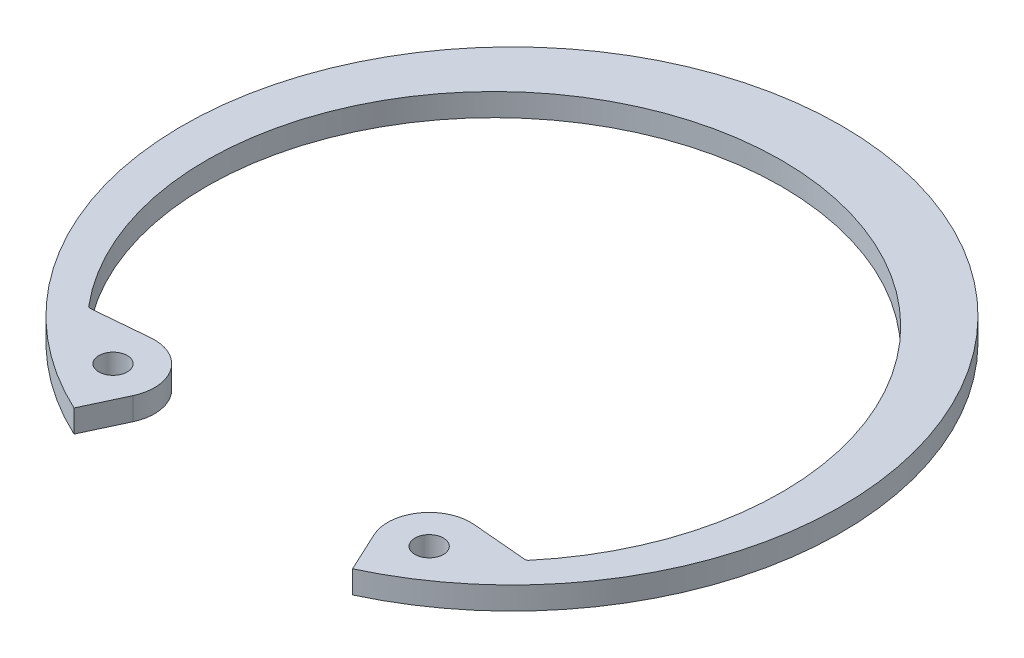
from build123d import *

# Parameters (mm, degrees)
SKETCH2_R      = 0.9906
EXTRUDE1_DEPTH = 1.5748
FILLET1_R      = 0.254


with BuildPart() as part:
    # Sketch2 → Extrude1 (new body)
    with BuildSketch(Plane(origin=(0, 0, 0), x_dir=(1, 0, 0), z_dir=(0, 1, 0))):
        with BuildLine():
            Line((9.682522471, -20.764236447), (8.376008921, -17.962409097))
            ThreePointArc((8.376008921, -17.962409097), (8.627270212, -15.090479402), (11.240064931, -13.872113215))
            Line((11.240064931, -13.872113215), (15.218174681, -14.22015272))
            ThreePointArc((15.218174681, -14.22015272), (0, 18.7452), (-15.218174681, -14.22015272))
            Line((-15.218174681, -14.22015272), (-11.240064931, -13.872113215))
            ThreePointArc((-11.240064931, -13.872113215), (-8.627270212, -15.090479402), (-8.376008921, -17.962409097))
            Line((-8.376008921, -17.962409097), (-9.682522471, -20.764236447))
            ThreePointArc((-9.682522471, -20.764236447), (0, 22.9108), (9.682522471, -20.764236447))
        make_face()
        with Locations((10.98880364, -16.74404291)):
            Circle(SKETCH2_R, mode=Mode.SUBTRACT)
        with Locations((-10.98880364, -16.74404291)):
            Circle(SKETCH2_R, mode=Mode.SUBTRACT)
    extrude(amount=-EXTRUDE1_DEPTH)

    # Fillet1
    fillet1_edges = [part.edges().sort_by_distance(p)[0] for p in [
        (15.218174681, -0.7874, 14.22015272),
        (-15.218174681, -0.7874, 14.22015272),
    ]]
    fillet(fillet1_edges, radius=FILLET1_R)


solid = part.part
